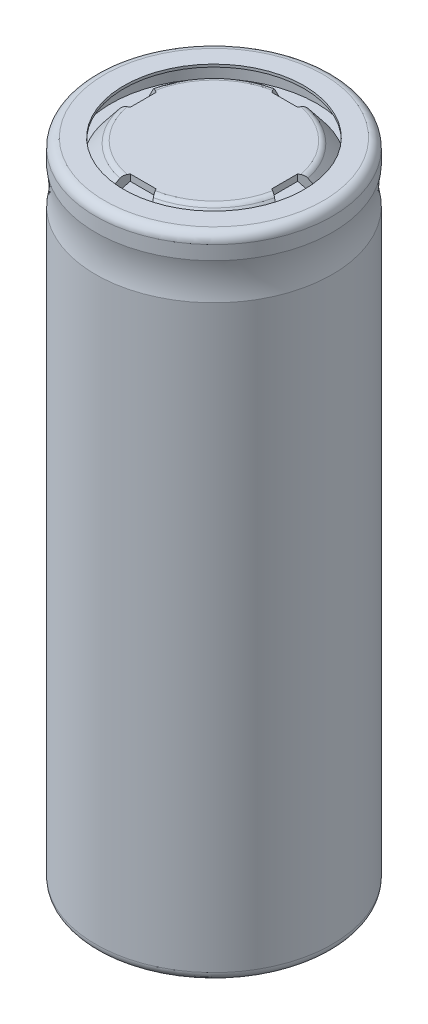
from build123d import *

# Parameters (mm, degrees)
CUT_EXTRUDE_1_DEPTH      = 1
CUT_EXTRUDE_1_DEPTH_BACK = 1.501485988


with BuildPart() as part:
    # Эскиз1 → Повернуть1 (revolve)
    with BuildSketch(Plane.XY):
        with BuildLine():
            Line((0, 0.5), (0, 0))
            Line((0, 0), (8.5, 0))
            ThreePointArc((8.5, 0), (8.853553391, 0.146446609), (9, 0.5))
            Line((9, 0.5), (9, 45.587272326))
            ThreePointArc((9, 45.587272326), (8.90824829, 45.875947461), (8.666666667, 46.058676847))
            ThreePointArc((8.666666667, 46.058676847), (8, 47.001485888), (8.666666667, 47.94429493))
            ThreePointArc((8.666666667, 47.94429493), (8.90824829, 48.127024316), (9, 48.415699451))
            Line((9, 48.415699451), (9, 49.5))
            ThreePointArc((9, 49.5), (8.498514112, 50.001485888), (7.997028223, 49.5))
            Line((7.997028223, 49.5), (7.997028223, 48.5))
            Line((7.997028223, 48.5), (7.2, 48.5))
            Line((7.2, 48.5), (6.150171734, 49.813585272))
            ThreePointArc((6.150171734, 49.813585272), (5.976233912, 49.95205247), (5.759462711, 50.00142632))
            Line((5.759462711, 50.00142632), (0, 50))
            Line((0, 50), (0, 49.5))
            Line((0, 49.5), (5.608751555, 49.5))
            Line((5.608751555, 49.5), (6.7, 48.5))
            Line((6.7, 48.5), (0, 48.5))
            Line((0, 48.5), (0, 48))
            Line((0, 48), (8.2, 48))
            Line((8.2, 48), (8.2, 48.5))
            Line((8.2, 48.5), (8.498514112, 48.5))
            Line((8.498514112, 48.5), (8.498514112, 48.415173231))
            ThreePointArc((8.498514112, 48.415173231), (8.406914027, 48.126712646), (8.165676074, 47.943944117))
            ThreePointArc((8.165676074, 47.943944117), (7.500000138, 47.00096045), (8.166666667, 46.058676847))
            ThreePointArc((8.166666667, 46.058676847), (8.40824829, 45.875947461), (8.5, 45.587272326))
            Line((8.5, 45.587272326), (8.5, 0.5))
            Line((8.5, 0.5), (0, 0.5))
        make_face()
    revolve(axis=Axis((0, 0, 0), (0, 1, 0)))

    # Эскиз2 → Вырез-Вытянуть1 (cut, two sides)
    with BuildSketch(Plane.XZ.offset(-49.5)) as cut_extrude_1_sk:
        Polygon((-1, -5.495703298), (1, -5.495703298), (2, -7.2), (-2, -7.2), align=None)
        Polygon((-5.495703298, 1), (-5.495703298, -1), (-7.2, -2), (-7.2, 2), align=None)
        Polygon((1, 5.495703298), (-1, 5.495703298), (-2, 7.2), (2, 7.2), align=None)
        Polygon((5.495703298, -1), (5.495703298, 1), (7.2, 2), (7.2, -2), align=None)
    extrude(amount=CUT_EXTRUDE_1_DEPTH, mode=Mode.SUBTRACT)
    extrude(cut_extrude_1_sk.sketch, amount=-CUT_EXTRUDE_1_DEPTH_BACK, mode=Mode.SUBTRACT)


with BuildPart() as body_2:
    # Эскиз3 → Повернуть4 (revolve)
    with BuildSketch(Plane.XY):
        with BuildLine():
            Line((8.497664073, 0), (7, 0))
            Line((7, 0), (7, -0.2))
            Line((7, -0.2), (8.5, -0.2))
            ThreePointArc((8.5, -0.2), (8.994974747, 0.005025253), (9.2, 0.5))
            Line((9.2, 0.5), (9.2, 45.587272326))
            add(Edge.make_bspline(
                [(9.2, 48.416313782), (8.901392965, 46.953947415), (9.2, 45.587272326)],
                knots=[0, 0, 0, 0.679954534, 0.679954534, 0.679954534], degree=2))
            Line((9.2, 48.416313782), (9.2, 49.5))
            ThreePointArc((9.2, 49.5), (8.99453954, 49.996025429), (8.498514112, 50.201485888))
            Line((8.498514112, 50.201485888), (7, 50.201485888))
            Line((7, 50.201485888), (7, 50.001485888))
            Line((7, 50.001485888), (8.496178619, 50.00148045))
            ThreePointArc((8.496178619, 50.00148045), (8.852291499, 49.855428835), (9, 49.5))
            Line((9, 49.5), (9, 48.415699451))
            add(Edge.make_bspline(
                [(9, 48.415699451), (8.697080045, 46.944299731), (9, 45.587272326)],
                knots=[0, 0, 0, 0.587527579, 0.587527579, 0.587527579], degree=2))
            Line((9, 45.587272326), (9, 0.5))
            ThreePointArc((9, 0.5), (8.885768464, 0.18190773), (8.595269231, 0.009160135))
            Line((8.595269231, 0.009160135), (8.497664073, 0))
        make_face()
    revolve(axis=Axis((0, -2.74002086, 0), (0, 1, 0)))


solid = Compound([part.part, body_2.part])
